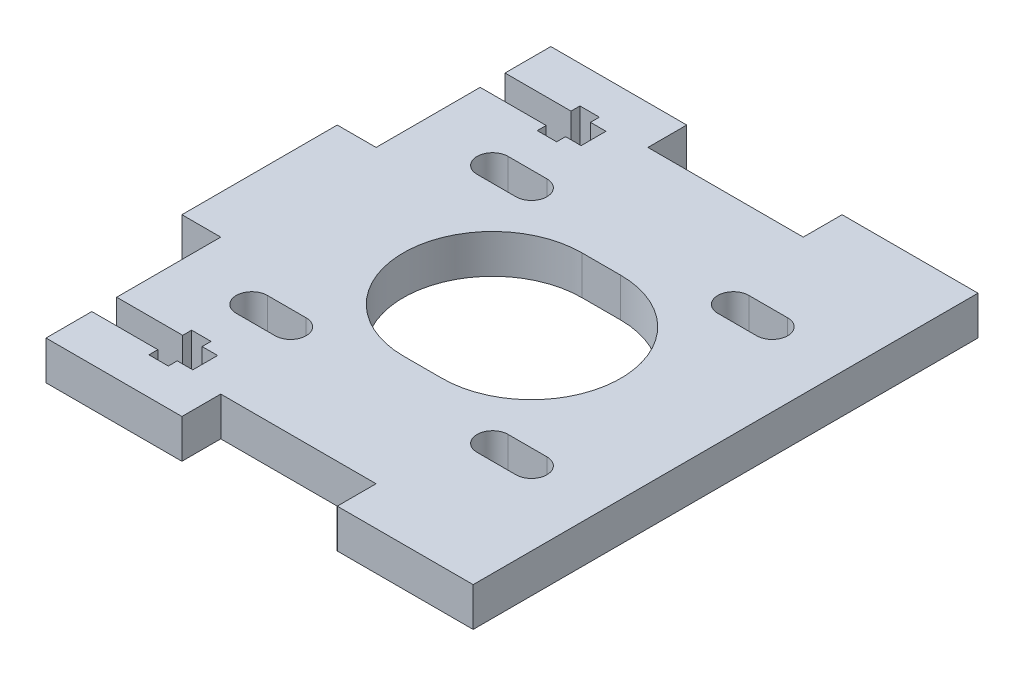
from build123d import *

# Parameters (mm, degrees)
BOSS_EXTRU_1_DEPTH      = 5
ENL_V_MAT_EXTRU_1_DEPTH = 5
ENL_V_MAT_EXTRU_2_DEPTH = 5
SYM_TRIE2_COPY_1_DEPTH  = 5
ENL_V_MAT_EXTRU_3_DEPTH = 10


with BuildPart() as part:
    # Esquisse1 → Boss.-Extru.1 (new body)
    with BuildSketch(Plane(origin=(0, 0, 0), x_dir=(1, 0, 0), z_dir=(0, 1, 0))):
        Polygon((17.5, -5), (37.5, -5), (37.5, 0), (55, 0), (55, -60), (55, -65), (37.5, -65), (37.5, -60), (17.5, -60), (17.5, -65), (0, -65), (0, -60), (0, -42.5), (-5, -42.5), (-5, -22.5), (0, -22.5), (0, 0), (17.5, 0), align=None)
    extrude(amount=BOSS_EXTRU_1_DEPTH)

    # Esquisse2 → Enlèv. mat.-Extru.1 (cut)
    with BuildSketch(Plane(origin=(0, 5, 0), x_dir=(1, 0, 0), z_dir=(0, 1, 0))):
        with BuildLine():
            Line((25, -21), (30, -21))
            ThreePointArc((30, -21), (41.5, -32.5), (30, -44))
            Line((30, -44), (25, -44))
            ThreePointArc((25, -44), (13.5, -32.5), (25, -21))
        make_face()
    extrude(amount=-ENL_V_MAT_EXTRU_1_DEPTH, mode=Mode.SUBTRACT)

    # Esquisse3 → Enlèv. mat.-Extru.2 (cut)
    with BuildSketch(Plane(origin=(0, 5, 0), x_dir=(1, 0, 0), z_dir=(0, 1, 0))):
        with BuildLine():
            Line((9.5, -15), (14.5, -15))
            ThreePointArc((14.5, -15), (16.5, -17), (14.5, -19))
            Line((14.5, -19), (9.5, -19))
            ThreePointArc((9.5, -19), (7.5, -17), (9.5, -15))
        make_face()
    enl_v_mat_extru_2 = extrude(amount=-ENL_V_MAT_EXTRU_2_DEPTH, mode=Mode.SUBTRACT)

    # Symétrie1: Enlèv. mat.-Extru.2 across plane
    add(enl_v_mat_extru_2.mirror(Plane.XY.offset(32.5)), mode=Mode.SUBTRACT)

    # Symétrie2: Enlèv. mat.-Extru.2 across plane
    add(enl_v_mat_extru_2.mirror(Plane.ZY.offset(-27.5)), mode=Mode.SUBTRACT)

    # Symétrie2 copy 1 sketch → Symétrie2 copy 1 (cut)
    with BuildSketch(Plane(origin=(55, 5, 65), x_dir=(-1, 0, 0), z_dir=(0, 1, 0))):
        with BuildLine():
            Line((9.5, -15), (14.5, -15))
            ThreePointArc((14.5, -15), (16.5, -17), (14.5, -19))
            Line((14.5, -19), (9.5, -19))
            ThreePointArc((9.5, -19), (7.5, -17), (9.5, -15))
        make_face()
    extrude(amount=-SYM_TRIE2_COPY_1_DEPTH, mode=Mode.SUBTRACT)

    # Esquisse4 → Enlèv. mat.-Extru.3 (cut)
    with BuildSketch(Plane(origin=(0, 5, 0), x_dir=(1, 0, 0), z_dir=(0, 1, 0))):
        Polygon((13, -5.9), (11, -5.9), (11, -4.75), (8.5, -4.75), (8.5, -5.9), (0, -5.9), (0, -9.1), (8.5, -9.1), (8.5, -10.25), (11, -10.25), (11, -9.1), (13, -9.1), align=None)
    enl_v_mat_extru_3 = extrude(amount=-ENL_V_MAT_EXTRU_3_DEPTH, mode=Mode.SUBTRACT)

    # Symétrie3: Enlèv. mat.-Extru.3 across plane
    add(enl_v_mat_extru_3.mirror(Plane.XY.offset(32.5)), mode=Mode.SUBTRACT)


solid = part.part
